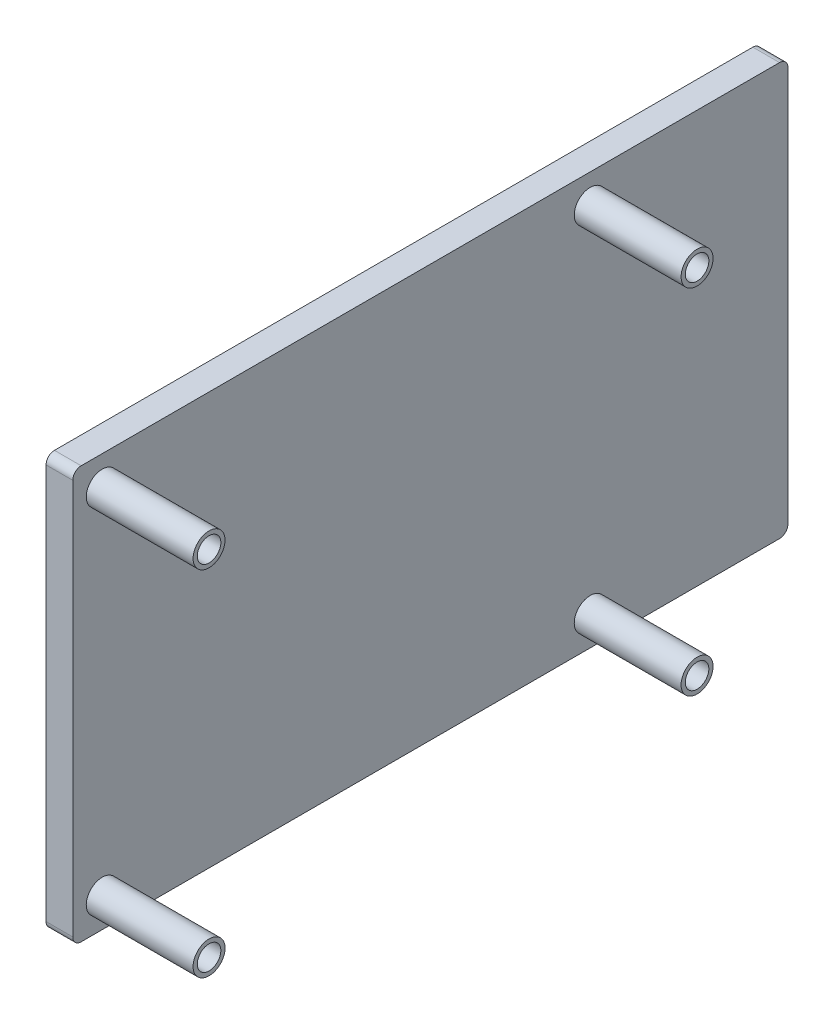
from build123d import *

# Parameters (mm, degrees)
SKETCH1_W           = 85
SKETCH1_H           = 49
BOSS_EXTRUDE1_DEPTH = 3.175
SKETCH2_R           = 1.9
SKETCH2_R_2         = 1.4
BOSS_EXTRUDE2_DEPTH = 12.7
FILLET1_R           = 1


with BuildPart() as part:
    # Sketch1 → Boss-Extrude1 (new body)
    with BuildSketch(Plane(origin=(0, 0, 0), x_dir=(0, 0, -1), z_dir=(1, 0, 0))):
        with Locations((-11.829824561, -9.198245614)):
            Rectangle(SKETCH1_W, SKETCH1_H)
    extrude(amount=BOSS_EXTRUDE1_DEPTH)

    # Sketch2 → Boss-Extrude2 (add)
    with BuildSketch(Plane(origin=(3.175, 0, 0), x_dir=(0, 0, -1), z_dir=(1, 0, 0))):
        with Locations((-50.829824561, 11.801754386)):
            Circle(SKETCH2_R)
        with Locations((-50.829824561, 11.801754386)):
            Circle(SKETCH2_R_2, mode=Mode.SUBTRACT)
        with Locations((7.170175439, 11.801754386)):
            Circle(SKETCH2_R)
        with Locations((7.170175439, 11.801754386)):
            Circle(SKETCH2_R_2, mode=Mode.SUBTRACT)
        with Locations((7.170175439, -30.198245614)):
            Circle(SKETCH2_R)
        with Locations((7.170175439, -30.198245614)):
            Circle(SKETCH2_R_2, mode=Mode.SUBTRACT)
        with Locations((-50.829824561, -30.198245614)):
            Circle(SKETCH2_R)
        with Locations((-50.829824561, -30.198245614)):
            Circle(SKETCH2_R_2, mode=Mode.SUBTRACT)
    extrude(amount=BOSS_EXTRUDE2_DEPTH)

    # Fillet1
    fillet1_edges = [part.edges().sort_by_distance(p)[0] for p in [
        (1.5875, 15.301754386, 54.329824561),
        (1.5875, 15.301754386, -30.670175439),
        (1.5875, -33.698245614, -30.670175439),
        (1.5875, -33.698245614, 54.329824561),
    ]]
    fillet(fillet1_edges, radius=FILLET1_R)


solid = part.part
